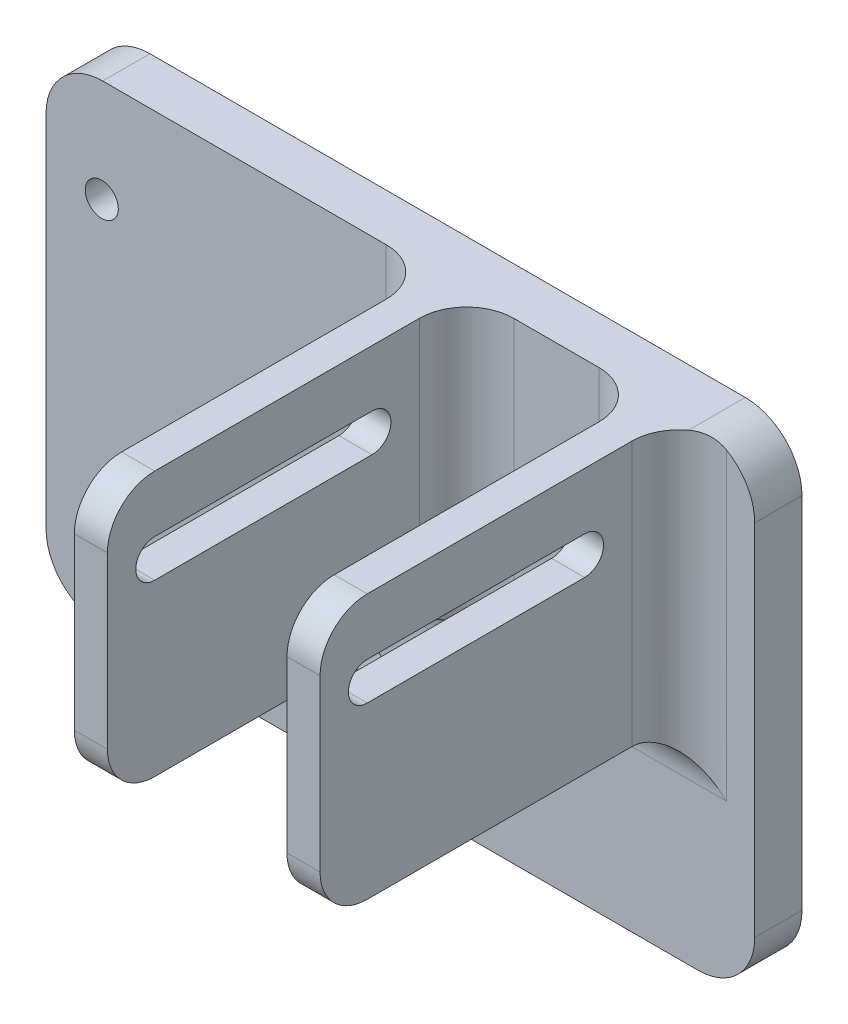
from build123d import *

# Parameters (mm, degrees)
SKETCH1_W               = 3.5
SKETCH1_H               = 28
BOSS_EXTRUDE1_DEPTH     = 38
BOSS_EXTRUDE1_2_DEPTH   = 38
SKETCH2_W               = 75
SKETCH2_H               = 50
BOSS_EXTRUDE2_DEPTH     = 5
FILLET1_R               = 6
FILLET2_R               = 5
CUT_EXTRUDE1_DEPTH      = 9.0000001
CUT_EXTRUDE1_DEPTH_BACK = 68
SKETCH4_R               = 1.75
CUT_EXTRUDE2_DEPTH      = 1.0000001
CUT_EXTRUDE2_DEPTH_BACK = 44


with BuildPart() as part:
    # Sketch1 → Boss-Extrude1 (new body)
    with BuildSketch(Plane.XY):
        with Locations((-11.25, 0)):
            Rectangle(SKETCH1_W, SKETCH1_H)
    extrude(amount=BOSS_EXTRUDE1_DEPTH)



with BuildPart() as body_2:
    # Sketch1 → Boss-Extrude1 2 (new body)
    with BuildSketch(Plane.XY):
        with Locations((11.25, 0)):
            Rectangle(SKETCH1_W, SKETCH1_H)
    extrude(amount=BOSS_EXTRUDE1_2_DEPTH)


with BuildPart() as part_1:
    add(part.part)

    add(body_2.part)  # Boss-Extrude2 merges body 2
    # Sketch2 → Boss-Extrude2 (add)
    with BuildSketch(Plane(origin=(0, 0, 0), x_dir=(-1, 0, 0), z_dir=(0, 0, -1))):
        with Locations((16.5, -11)):
            Rectangle(SKETCH2_W, SKETCH2_H)
    extrude(amount=BOSS_EXTRUDE2_DEPTH)

    # Fillet1
    fillet1_edges = [part_1.edges().sort_by_distance(p)[0] for p in [
        (-54, 14, -2.5),
        (21, 14, -2.5),
        (21, -36, -2.5),
        (-54, -36, -2.5),
    ]]
    fillet(fillet1_edges, radius=FILLET1_R)

    # Fillet2
    fillet2_edges = [part_1.edges().sort_by_distance(p)[0] for p in [
        (-11.25, 14, 38),
        (11.25, -14, 0),
        (13, 0, 0),
        (11.25, 14, 38),
        (11.25, -14, 38),
        (9.5, 0, 0),
        (-11.25, -14, 38),
        (-13, 0, 0),
        (-9.5, 0, 0),
        (-11.25, -14, 0),
    ]]
    fillet(fillet2_edges, radius=FILLET2_R)

    # Sketch3 → Cut-Extrude1 (cut, two sides)
    with BuildSketch(Plane(origin=(13, 0, 0), x_dir=(0, 0, -1), z_dir=(1, 0, 0))) as cut_extrude1_sk:
        with BuildLine():
            Line((-10, 4), (-33, 4))
            ThreePointArc((-33, 4), (-35, 6), (-33, 8))
            Line((-33, 8), (-10, 8))
            ThreePointArc((-10, 8), (-8, 6), (-10, 4))
        make_face()
    extrude(amount=CUT_EXTRUDE1_DEPTH, mode=Mode.SUBTRACT)
    extrude(cut_extrude1_sk.sketch, amount=-CUT_EXTRUDE1_DEPTH_BACK, mode=Mode.SUBTRACT)

    # Sketch4 → Cut-Extrude2 (cut, two sides)
    with BuildSketch(Plane(origin=(0, 0, -5), x_dir=(-1, 0, 0), z_dir=(0, 0, -1))) as cut_extrude2_sk:
        with Locations((19.9, 3.1)):
            Circle(SKETCH4_R)
        with Locations((48.1, 3.1)):
            Circle(SKETCH4_R)
        with Locations((48.1, -25.1)):
            Circle(SKETCH4_R)
        with Locations((19.9, -25.1)):
            Circle(SKETCH4_R)
    extrude(amount=CUT_EXTRUDE2_DEPTH, mode=Mode.SUBTRACT)
    extrude(cut_extrude2_sk.sketch, amount=-CUT_EXTRUDE2_DEPTH_BACK, mode=Mode.SUBTRACT)


solid = part_1.part
